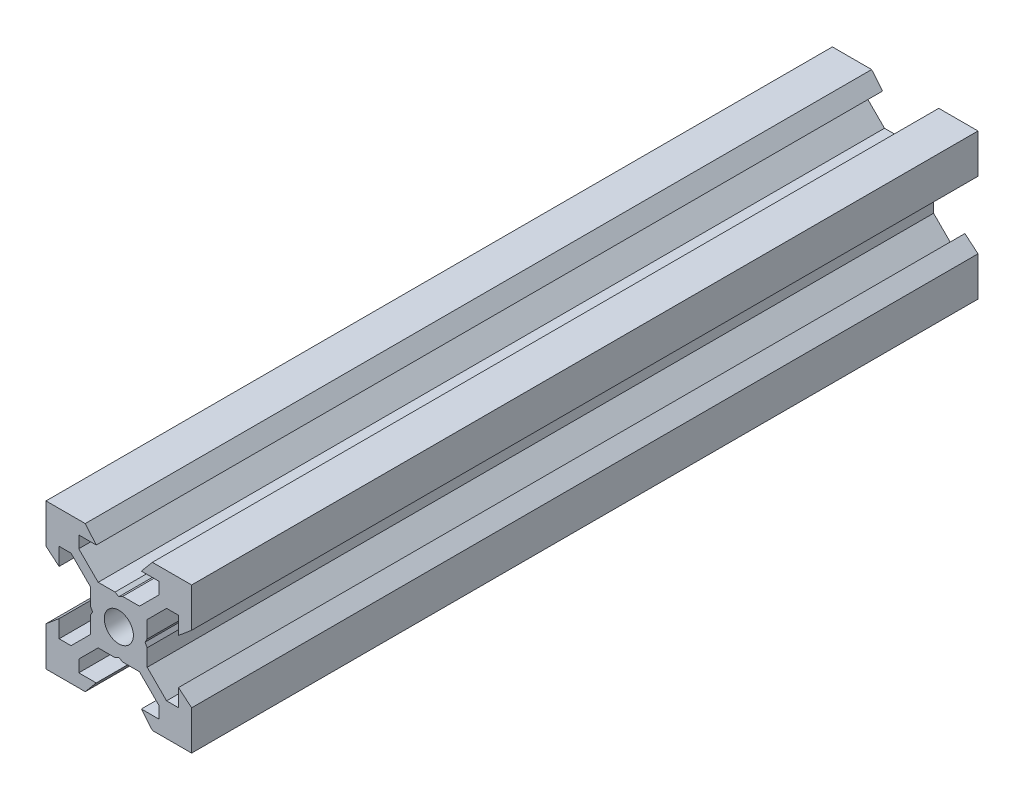
from build123d import *

# Parameters (mm, degrees)
SKETCH1_R           = 2
BOSS_EXTRUDE1_DEPTH = 54


with BuildPart() as part:
    # Sketch1 → Boss-Extrude1 (new body, symmetric)
    with BuildSketch(Plane.XY):
        Polygon((10, 10), (10, 4.610379336), (8.2, 3.1), (8.2, 5.5), (6.560660172, 5.5), (3.9, 2.839339828), (3.9, 0.519615242), (3.6, 0), (3.9, -0.519615242), (3.9, -2.839339828), (6.560660172, -5.5), (8.2, -5.5), (8.2, -3.1), (10, -4.610379336), (10, -10), (4.610379336, -10), (3.1, -8.2), (5.5, -8.2), (5.5, -6.560660172), (2.839339828, -3.9), (0.519615242, -3.9), (0, -3.6), (-0.519615242, -3.9), (-2.839339828, -3.9), (-5.5, -6.560660172), (-5.5, -8.2), (-3.1, -8.2), (-4.610379336, -10), (-10, -10), (-10, -4.610379336), (-8.2, -3.1), (-8.2, -5.5), (-6.560660172, -5.5), (-3.9, -2.839339828), (-3.9, -0.519615242), (-3.6, 0), (-3.9, 0.519615242), (-3.9, 2.839339828), (-6.560660172, 5.5), (-8.2, 5.5), (-8.2, 3.1), (-10, 4.610379336), (-10, 10), (-4.610379336, 10), (-3.1, 8.2), (-5.5, 8.2), (-5.5, 6.560660172), (-2.839339828, 3.9), (-0.519615242, 3.9), (0, 3.6), (0.519615242, 3.9), (2.839339828, 3.9), (5.5, 6.560660172), (5.5, 8.2), (3.1, 8.2), (4.610379336, 10), align=None)
        Circle(SKETCH1_R, mode=Mode.SUBTRACT)
    extrude(amount=BOSS_EXTRUDE1_DEPTH, both=True)


solid = part.part
